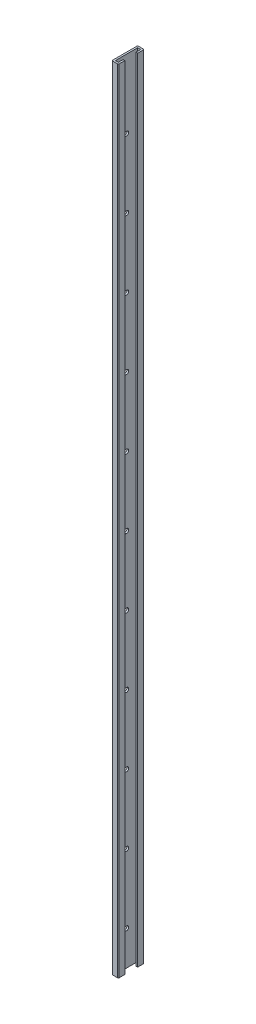
from build123d import *

# Parameters (mm, degrees)
BOSS_EXTRUDE1_DEPTH = 1168.4
CUT_EXTRUDE1_REACH  = 4.54
SKETCH2_R           = 3.175


with BuildPart() as part:
    # Sketch1 → Boss-Extrude1 (new body)
    with BuildSketch(Plane(origin=(0, 0, 0), x_dir=(1, 0, 0), z_dir=(0, 1, 0))):
        with BuildLine():
            Line((9.525, 34.29), (9.525, 26.035))
            Line((9.525, 26.035), (6.985, 26.035))
            Line((6.985, 26.035), (6.985, 33.02))
            Line((6.985, 33.02), (2.54, 33.02))
            Line((2.54, 33.02), (2.54, 0))
            Line((2.54, 0), (6.985, 0))
            Line((6.985, 0), (6.985, 6.985))
            Line((6.985, 6.985), (9.525, 6.985))
            Line((9.525, 6.985), (9.525, -1.27))
            ThreePointArc((9.525, -1.27), (9.153025612, -2.168025612), (8.255, -2.54))
            Line((8.255, -2.54), (1.27, -2.54))
            ThreePointArc((1.27, -2.54), (0.371974388, -2.168025612), (0, -1.27))
            Line((0, -1.27), (0, 34.29))
            ThreePointArc((0, 34.29), (0.371974388, 35.188025612), (1.27, 35.56))
            Line((1.27, 35.56), (8.255, 35.56))
            ThreePointArc((8.255, 35.56), (9.153025612, 35.188025612), (9.525, 34.29))
        make_face()
    extrude(amount=BOSS_EXTRUDE1_DEPTH)

    # Sketch2 → Cut-Extrude1 (cut, up to next)
    with BuildSketch(Plane(origin=(2.54, 0, 0), x_dir=(0, 0, -1), z_dir=(1, 0, 0)), mode=Mode.PRIVATE) as cut_extrude1_sk1:
        with Locations((16.51, 50.8)):
            Circle(SKETCH2_R)
    cut_extrude1_tool1 = extrude(cut_extrude1_sk1.sketch, amount=-CUT_EXTRUDE1_REACH, mode=Mode.PRIVATE) & part.part
    add(cut_extrude1_tool1.solids().sort_by_distance((2.54, 50.8, -16.51))[0], mode=Mode.SUBTRACT)
    # Sketch2 → Cut-Extrude1 (cut, up to next)
    with BuildSketch(Plane(origin=(2.54, 0, 0), x_dir=(0, 0, -1), z_dir=(1, 0, 0)), mode=Mode.PRIVATE) as cut_extrude1_sk2:
        with Locations((16.51, 152.4)):
            Circle(SKETCH2_R)
    cut_extrude1_tool2 = extrude(cut_extrude1_sk2.sketch, amount=-CUT_EXTRUDE1_REACH, mode=Mode.PRIVATE) & part.part
    add(cut_extrude1_tool2.solids().sort_by_distance((2.54, 152.4, -16.51))[0], mode=Mode.SUBTRACT)
    # Sketch2 → Cut-Extrude1 (cut, up to next)
    with BuildSketch(Plane(origin=(2.54, 0, 0), x_dir=(0, 0, -1), z_dir=(1, 0, 0)), mode=Mode.PRIVATE) as cut_extrude1_sk3:
        with Locations((16.51, 254)):
            Circle(SKETCH2_R)
    cut_extrude1_tool3 = extrude(cut_extrude1_sk3.sketch, amount=-CUT_EXTRUDE1_REACH, mode=Mode.PRIVATE) & part.part
    add(cut_extrude1_tool3.solids().sort_by_distance((2.54, 254, -16.51))[0], mode=Mode.SUBTRACT)
    # Sketch2 → Cut-Extrude1 (cut, up to next)
    with BuildSketch(Plane(origin=(2.54, 0, 0), x_dir=(0, 0, -1), z_dir=(1, 0, 0)), mode=Mode.PRIVATE) as cut_extrude1_sk4:
        with Locations((16.51, 355.6)):
            Circle(SKETCH2_R)
    cut_extrude1_tool4 = extrude(cut_extrude1_sk4.sketch, amount=-CUT_EXTRUDE1_REACH, mode=Mode.PRIVATE) & part.part
    add(cut_extrude1_tool4.solids().sort_by_distance((2.54, 355.6, -16.51))[0], mode=Mode.SUBTRACT)
    # Sketch2 → Cut-Extrude1 (cut, up to next)
    with BuildSketch(Plane(origin=(2.54, 0, 0), x_dir=(0, 0, -1), z_dir=(1, 0, 0)), mode=Mode.PRIVATE) as cut_extrude1_sk5:
        with Locations((16.51, 457.2)):
            Circle(SKETCH2_R)
    cut_extrude1_tool5 = extrude(cut_extrude1_sk5.sketch, amount=-CUT_EXTRUDE1_REACH, mode=Mode.PRIVATE) & part.part
    add(cut_extrude1_tool5.solids().sort_by_distance((2.54, 457.2, -16.51))[0], mode=Mode.SUBTRACT)
    # Sketch2 → Cut-Extrude1 (cut, up to next)
    with BuildSketch(Plane(origin=(2.54, 0, 0), x_dir=(0, 0, -1), z_dir=(1, 0, 0)), mode=Mode.PRIVATE) as cut_extrude1_sk6:
        with Locations((16.51, 558.8)):
            Circle(SKETCH2_R)
    cut_extrude1_tool6 = extrude(cut_extrude1_sk6.sketch, amount=-CUT_EXTRUDE1_REACH, mode=Mode.PRIVATE) & part.part
    add(cut_extrude1_tool6.solids().sort_by_distance((2.54, 558.8, -16.51))[0], mode=Mode.SUBTRACT)
    # Sketch2 → Cut-Extrude1 (cut, up to next)
    with BuildSketch(Plane(origin=(2.54, 0, 0), x_dir=(0, 0, -1), z_dir=(1, 0, 0)), mode=Mode.PRIVATE) as cut_extrude1_sk7:
        with Locations((16.51, 660.4)):
            Circle(SKETCH2_R)
    cut_extrude1_tool7 = extrude(cut_extrude1_sk7.sketch, amount=-CUT_EXTRUDE1_REACH, mode=Mode.PRIVATE) & part.part
    add(cut_extrude1_tool7.solids().sort_by_distance((2.54, 660.4, -16.51))[0], mode=Mode.SUBTRACT)
    # Sketch2 → Cut-Extrude1 (cut, up to next)
    with BuildSketch(Plane(origin=(2.54, 0, 0), x_dir=(0, 0, -1), z_dir=(1, 0, 0)), mode=Mode.PRIVATE) as cut_extrude1_sk8:
        with Locations((16.51, 762)):
            Circle(SKETCH2_R)
    cut_extrude1_tool8 = extrude(cut_extrude1_sk8.sketch, amount=-CUT_EXTRUDE1_REACH, mode=Mode.PRIVATE) & part.part
    add(cut_extrude1_tool8.solids().sort_by_distance((2.54, 762, -16.51))[0], mode=Mode.SUBTRACT)
    # Sketch2 → Cut-Extrude1 (cut, up to next)
    with BuildSketch(Plane(origin=(2.54, 0, 0), x_dir=(0, 0, -1), z_dir=(1, 0, 0)), mode=Mode.PRIVATE) as cut_extrude1_sk9:
        with Locations((16.51, 863.6)):
            Circle(SKETCH2_R)
    cut_extrude1_tool9 = extrude(cut_extrude1_sk9.sketch, amount=-CUT_EXTRUDE1_REACH, mode=Mode.PRIVATE) & part.part
    add(cut_extrude1_tool9.solids().sort_by_distance((2.54, 863.6, -16.51))[0], mode=Mode.SUBTRACT)
    # Sketch2 → Cut-Extrude1 (cut, up to next)
    with BuildSketch(Plane(origin=(2.54, 0, 0), x_dir=(0, 0, -1), z_dir=(1, 0, 0)), mode=Mode.PRIVATE) as cut_extrude1_sk10:
        with Locations((16.51, 965.2)):
            Circle(SKETCH2_R)
    cut_extrude1_tool10 = extrude(cut_extrude1_sk10.sketch, amount=-CUT_EXTRUDE1_REACH, mode=Mode.PRIVATE) & part.part
    add(cut_extrude1_tool10.solids().sort_by_distance((2.54, 965.2, -16.51))[0], mode=Mode.SUBTRACT)
    # Sketch2 → Cut-Extrude1 (cut, up to next)
    with BuildSketch(Plane(origin=(2.54, 0, 0), x_dir=(0, 0, -1), z_dir=(1, 0, 0)), mode=Mode.PRIVATE) as cut_extrude1_sk11:
        with Locations((16.51, 1066.8)):
            Circle(SKETCH2_R)
    cut_extrude1_tool11 = extrude(cut_extrude1_sk11.sketch, amount=-CUT_EXTRUDE1_REACH, mode=Mode.PRIVATE) & part.part
    add(cut_extrude1_tool11.solids().sort_by_distance((2.54, 1066.8, -16.51))[0], mode=Mode.SUBTRACT)


solid = part.part
